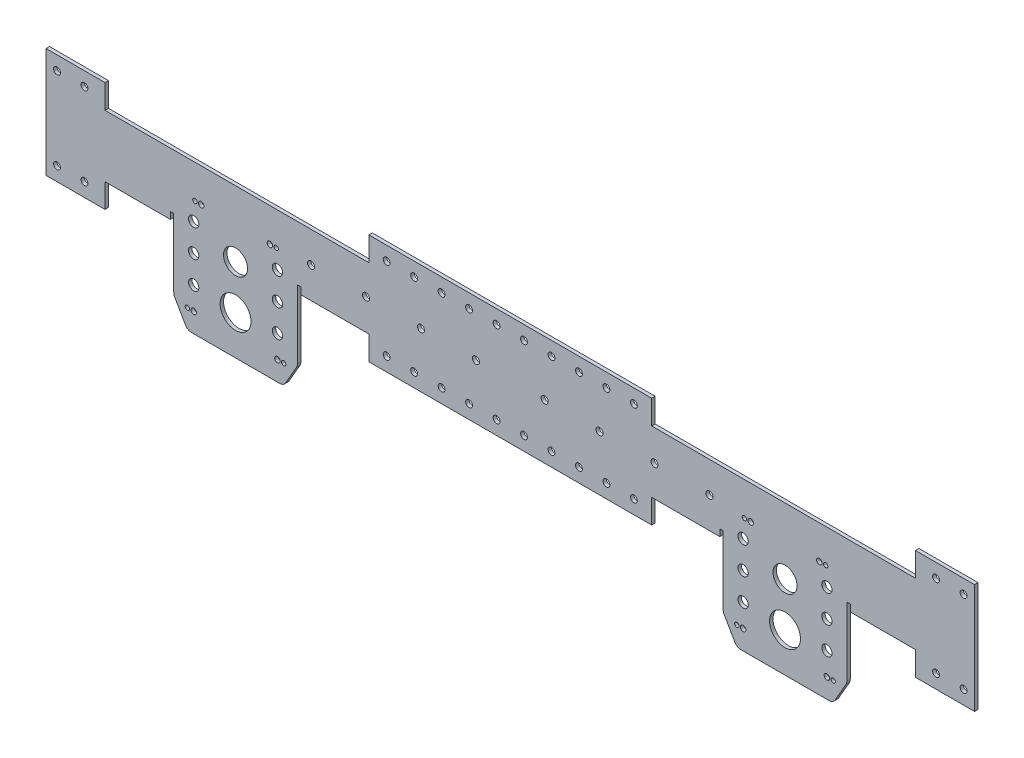
from build123d import *
from build123d.topology import SkipClean

# Parameters (mm, degrees)
SKETCH1_R            = 6.35
BOSS_EXTRUDE1_DEPTH  = 3.175
SKETCH2_W            = 596.9
SKETCH2_H            = 3.175
BOSS_EXTRUDE2_DEPTH  = 25.4
FILLET1_R            = 2.54
SKETCH3_R            = 3.2639
CUT_EXTRUDE1_DEPTH   = 25.4
SKETCH5_R            = 3.2639
CUT_EXTRUDE2_DEPTH   = 25.4
SKETCH6_W            = 31.75
SKETCH6_H            = 44.45
BOSS_EXTRUDE3_DEPTH  = 3.175
SKETCH7_W            = 31.75
SKETCH7_H            = 3.175
SKETCH7_W_2          = 381
BOSS_EXTRUDE4_DEPTH  = 25.4
FILLET2_R            = 2.54
SKETCH8_R            = 3.2639
CUT_EXTRUDE3_DEPTH   = 177.8
SKETCH9_R            = 3.2639
CUT_EXTRUDE5_DEPTH   = 432.308
BOSS_EXTRUDE6_DEPTH  = 66.675
BOSS_EXTRUDE7_START  = 66.675
BOSS_EXTRUDE7_DEPTH  = 66.675
SKETCH12_R           = 6.35
SKETCH12_R_2         = 3.2639
SKETCH12_W           = 256.6289
SKETCH12_H           = 252.715944366
CUT_EXTRUDE8_DEPTH   = 66.675
BOSS_EXTRUDE8_START  = 19.05
BOSS_EXTRUDE8_DEPTH  = 19.05
BOSS_EXTRUDE9_DEPTH  = 19.05
SKETCH16_R           = 3.2639
CUT_EXTRUDE9_DEPTH   = 133.096
SKETCH17_R           = 3.175
CUT_EXTRUDE11_DEPTH  = 5.08
SKETCH18_W           = 256.6289
SKETCH18_H           = 3.175
SKETCH18_W_2         = 838.2
BOSS_EXTRUDE10_DEPTH = 3.175
SKETCH19_W           = 107.950440108
SKETCH19_H           = 6.388661832
SKETCH19_W_2         = 107.95
SKETCH19_H_2         = 3.175
CUT_EXTRUDE12_DEPTH  = 3.175
SKETCH20_W           = 555.272296498
SKETCH20_H           = 244.428342312
SKETCH20_R           = 3.2639
SKETCH20_R_2         = 6.35
SKETCH20_R_3         = 3.175
CUT_EXTRUDE13_DEPTH  = 277.622
BOSS_EXTRUDE11_START = -3.175
SKETCH21_R           = 6.35
BOSS_EXTRUDE11_DEPTH = 3.175
SKETCH22_W           = 47.625
SKETCH22_H           = 22.225
SKETCH22_W_2         = 236.0422
BOSS_EXTRUDE12_DEPTH = 3.175
SKETCH23_W           = 47.625
SKETCH23_H           = 22.225
SKETCH23_W_2         = 236.0422
BOSS_EXTRUDE14_DEPTH = 3.175
BOSS_EXTRUDE15_DEPTH = 12.7
BOSS_EXTRUDE16_START = 12.7
BOSS_EXTRUDE16_DEPTH = 12.7
SKETCH27_R           = 3.175
CUT_EXTRUDE15_DEPTH  = 76.2
SKETCH28_W           = 22.225
SKETCH28_H           = 3.175
BOSS_EXTRUDE17_DEPTH = 12.7
SKETCH29_W           = 22.225
SKETCH29_H           = 3.175
BOSS_EXTRUDE18_DEPTH = 12.7
SKETCH30_R           = 6.35
SKETCH30_R_2         = 5.185373
SKETCH30_R_3         = 5.538595338
BOSS_EXTRUDE19_DEPTH = 3.175
SKETCH31_R           = 14.2875
SKETCH31_R_2         = 11.1125
SKETCH31_R_3         = 4.7625
SKETCH31_R_4         = 2.54
SKETCH31_R_5         = 2.032
CUT_EXTRUDE17_DEPTH  = 3.175
BOSS_EXTRUDE21_DEPTH = 3.175
FILLET4_R            = 6.35
SKETCH34_W           = 94.166192965
SKETCH34_H           = 14.648074461
BOSS_EXTRUDE22_DEPTH = 3.175
SKETCH35_R           = 2.54
SKETCH35_R_2         = 2.032
CUT_EXTRUDE19_DEPTH  = 3.175
SKETCH36_W           = 101.173518356
SKETCH36_H           = 13.169600398
BOSS_EXTRUDE24_DEPTH = 3.175
SKETCH37_W           = 9.525
SKETCH37_H           = 3.175
SKETCH37_W_2         = 3.175
CUT_EXTRUDE20_DEPTH  = 3.175
CUT_EXTRUDE21_START  = -3.175
CUT_EXTRUDE21_DEPTH  = 3.175
CUT_EXTRUDE22_DEPTH  = 3.175
CUT_EXTRUDE23_DEPTH  = 2.54
CUT_EXTRUDE24_START  = -2.54
CUT_EXTRUDE24_DEPTH  = 2.54
BOSS_EXTRUDE25_DEPTH = 3.175
SKETCH43_R           = 3.175
CUT_EXTRUDE25_DEPTH  = 3.175
SKETCH44_W           = 932.107852937
SKETCH44_H           = 79.647117721
CUT_EXTRUDE26_DEPTH  = 76.2


with BuildPart() as part:
    # Sketch1 → Boss-Extrude1 (new body)
    with BuildSketch(Plane.XY):
        with BuildLine():
            Line((50.8, 0), (50.8, 25.4))
            ThreePointArc((50.8, 25.4), (52.659871939, 29.890128061), (57.15, 31.75))
            Line((57.15, 31.75), (438.15, 31.75))
            ThreePointArc((438.15, 31.75), (442.640128061, 29.890128061), (444.5, 25.4))
            Line((444.5, 25.4), (444.5, 0))
            ThreePointArc((444.5, 0), (495.3, -50.8), (546.1, 0))
            Line((546.1, 0), (546.1, 76.2))
            Line((546.1, 76.2), (-50.8, 76.2))
            Line((-50.8, 76.2), (-50.8, 0))
            ThreePointArc((-50.8, 0), (0, -50.8), (50.8, 0))
        make_face()
        Circle(SKETCH1_R, mode=Mode.SUBTRACT)
        with Locations((495.3, 0)):
            Circle(SKETCH1_R, mode=Mode.SUBTRACT)
    extrude(amount=BOSS_EXTRUDE1_DEPTH)

    # Sketch2 → Boss-Extrude2 (add)
    with BuildSketch(Plane.XY.offset(3.175)):
        with Locations((247.65, 74.6125)):
            Rectangle(SKETCH2_W, SKETCH2_H)
    extrude(amount=BOSS_EXTRUDE2_DEPTH)

    # Fillet1
    fillet1_edges = [part.edges().sort_by_distance(p)[0] for p in [
        (247.65, 73.025, 3.175),
        (247.65, 76.2, 0),
    ]]
    fillet(fillet1_edges, radius=FILLET1_R)

    # Sketch3 → Cut-Extrude1 (cut)
    with BuildSketch(Plane(origin=(0, 76.2, 0), x_dir=(1, 0, 0), z_dir=(0, 1, 0))):
        with Locations((527.05, -15.5575)):
            Circle(SKETCH3_R)
        with Locations((501.65, -15.5575)):
            Circle(SKETCH3_R)
        with Locations((476.25, -15.5575)):
            Circle(SKETCH3_R)
        with Locations((450.85, -15.5575)):
            Circle(SKETCH3_R)
        with Locations((425.45, -15.5575)):
            Circle(SKETCH3_R)
        with Locations((400.05, -15.5575)):
            Circle(SKETCH3_R)
        with Locations((374.65, -15.5575)):
            Circle(SKETCH3_R)
        with Locations((349.25, -15.5575)):
            Circle(SKETCH3_R)
        with Locations((323.85, -15.5575)):
            Circle(SKETCH3_R)
        with Locations((298.45, -15.5575)):
            Circle(SKETCH3_R)
        with Locations((273.05, -15.5575)):
            Circle(SKETCH3_R)
        with Locations((247.65, -15.5575)):
            Circle(SKETCH3_R)
        with Locations((222.25, -15.5575)):
            Circle(SKETCH3_R)
        with Locations((196.85, -15.5575)):
            Circle(SKETCH3_R)
        with Locations((171.45, -15.5575)):
            Circle(SKETCH3_R)
        with Locations((146.05, -15.5575)):
            Circle(SKETCH3_R)
        with Locations((120.65, -15.5575)):
            Circle(SKETCH3_R)
        with Locations((95.25, -15.5575)):
            Circle(SKETCH3_R)
        with Locations((69.85, -15.5575)):
            Circle(SKETCH3_R)
        with Locations((44.45, -15.5575)):
            Circle(SKETCH3_R)
        with Locations((19.05, -15.5575)):
            Circle(SKETCH3_R)
        with Locations((-6.35, -15.5575)):
            Circle(SKETCH3_R)
        with Locations((-31.75, -15.5575)):
            Circle(SKETCH3_R)
    extrude(amount=-CUT_EXTRUDE1_DEPTH, mode=Mode.SUBTRACT)

    # Sketch5 → Cut-Extrude2 (cut)
    with BuildSketch(Plane(origin=(0, 0, 0), x_dir=(-1, 0, 0), z_dir=(0, 0, -1))):
        with Locations((-425.45, 53.975)):
            Circle(SKETCH5_R)
        with Locations((-374.65, 53.975)):
            Circle(SKETCH5_R)
        with Locations((-323.85, 53.975)):
            Circle(SKETCH5_R)
        with Locations((-273.05, 53.975)):
            Circle(SKETCH5_R)
        with Locations((-222.25, 53.975)):
            Circle(SKETCH5_R)
        with Locations((-171.45, 53.975)):
            Circle(SKETCH5_R)
        with Locations((-120.65, 53.975)):
            Circle(SKETCH5_R)
        with Locations((-69.85, 53.975)):
            Circle(SKETCH5_R)
    extrude(amount=-CUT_EXTRUDE2_DEPTH, mode=Mode.SUBTRACT)

    # Sketch6 → Boss-Extrude3 (add)
    with BuildSketch(Plane.XY.offset(3.175)):
        with Locations((-66.675, 53.975)):
            Rectangle(SKETCH6_W, SKETCH6_H)
        with Locations((561.975, 53.975)):
            Rectangle(SKETCH6_W, SKETCH6_H)
    extrude(amount=-BOSS_EXTRUDE3_DEPTH)

    # Sketch7 → Boss-Extrude4 (add)
    with BuildSketch(Plane.XY.offset(3.175)):
        with Locations((-66.675, 74.6125)):
            Rectangle(SKETCH7_W, SKETCH7_H)
        with Locations((-66.675, 33.3375)):
            Rectangle(SKETCH7_W, SKETCH7_H)
        with Locations((561.975, 74.6125)):
            Rectangle(SKETCH7_W, SKETCH7_H)
        with Locations((561.975, 33.3375)):
            Rectangle(SKETCH7_W, SKETCH7_H)
        with Locations((247.65, 33.3375)):
            Rectangle(SKETCH7_W_2, SKETCH7_H)
    extrude(amount=BOSS_EXTRUDE4_DEPTH)

    # Fillet2
    fillet2_edges = [part.edges().sort_by_distance(p)[0] for p in [
        (-50.8, 15.875, 0),
        (0, -50.8, 0),
        (50.8, 12.7, 0),
        (52.659871939, 29.890128061, 0),
        (546.1, 15.875, 0),
        (495.3, -50.8, 0),
        (444.5, 12.7, 0),
        (442.640128061, 29.890128061, 0),
        (-66.675, 34.925, 3.175),
        (-66.675, 31.75, 0),
        (247.65, 31.75, 0),
        (247.65, 34.925, 3.175),
        (561.975, 34.925, 3.175),
        (561.975, 31.75, 0),
        (561.975, 76.2, 0),
        (-66.675, 76.2, 0),
    ]]
    fillet(fillet2_edges, radius=FILLET2_R)

    # Sketch8 → Cut-Extrude3 (cut)
    with BuildSketch(Plane(origin=(0, 76.2, 0), x_dir=(1, 0, 0), z_dir=(0, 1, 0))):
        with Locations((-31.75, -15.5575)):
            Circle(SKETCH8_R)
        with Locations((-57.15, -15.5575)):
            Circle(SKETCH8_R)
        with Locations((-6.35, -15.5575)):
            Circle(SKETCH8_R)
        with Locations((19.05, -15.5575)):
            Circle(SKETCH8_R)
        with Locations((44.45, -15.5575)):
            Circle(SKETCH8_R)
        with Locations((69.85, -15.5575)):
            Circle(SKETCH8_R)
        with Locations((95.25, -15.5575)):
            Circle(SKETCH8_R)
        with Locations((120.65, -15.5575)):
            Circle(SKETCH8_R)
        with Locations((146.05, -15.5575)):
            Circle(SKETCH8_R)
        with Locations((171.45, -15.5575)):
            Circle(SKETCH8_R)
        with Locations((196.85, -15.5575)):
            Circle(SKETCH8_R)
        with Locations((222.25, -15.5575)):
            Circle(SKETCH8_R)
        with Locations((247.65, -15.5575)):
            Circle(SKETCH8_R)
        with Locations((273.05, -15.5575)):
            Circle(SKETCH8_R)
        with Locations((298.45, -15.5575)):
            Circle(SKETCH8_R)
        with Locations((323.85, -15.5575)):
            Circle(SKETCH8_R)
        with Locations((349.25, -15.5575)):
            Circle(SKETCH8_R)
        with Locations((374.65, -15.5575)):
            Circle(SKETCH8_R)
        with Locations((400.05, -15.5575)):
            Circle(SKETCH8_R)
        with Locations((425.45, -15.5575)):
            Circle(SKETCH8_R)
        with Locations((450.85, -15.5575)):
            Circle(SKETCH8_R)
        with Locations((476.25, -15.5575)):
            Circle(SKETCH8_R)
        with Locations((501.65, -15.5575)):
            Circle(SKETCH8_R)
        with Locations((527.05, -15.5575)):
            Circle(SKETCH8_R)
        with Locations((552.45, -15.5575)):
            Circle(SKETCH8_R)
    extrude(amount=-CUT_EXTRUDE3_DEPTH, mode=Mode.SUBTRACT)

    # Sketch9 → Cut-Extrude5 (cut)
    with BuildSketch(Plane(origin=(0, 76.2, 0), x_dir=(1, 0, 0), z_dir=(0, 1, 0))):
        with BuildLine():
            Line((298.45, -18.8214), (298.45, -28.575))
            Line((298.45, -28.575), (746.392900795, -28.575))
            Line((746.392900795, -28.575), (746.392900795, 89.004110939))
            Line((746.392900795, 89.004110939), (298.45, 89.004110939))
            Line((298.45, 89.004110939), (298.45, -12.2936))
            ThreePointArc((298.45, -12.2936), (301.7139, -15.5575), (298.45, -18.8214))
        make_face()
        with Locations((323.85, -15.5575)):
            Circle(SKETCH9_R, mode=Mode.SUBTRACT)
        with Locations((349.25, -15.5575)):
            Circle(SKETCH9_R, mode=Mode.SUBTRACT)
        with Locations((374.65, -15.5575)):
            Circle(SKETCH9_R, mode=Mode.SUBTRACT)
        with Locations((400.05, -15.5575)):
            Circle(SKETCH9_R, mode=Mode.SUBTRACT)
        with Locations((425.45, -15.5575)):
            Circle(SKETCH9_R, mode=Mode.SUBTRACT)
        with Locations((450.85, -15.5575)):
            Circle(SKETCH9_R, mode=Mode.SUBTRACT)
        with Locations((476.25, -15.5575)):
            Circle(SKETCH9_R, mode=Mode.SUBTRACT)
        with Locations((501.65, -15.5575)):
            Circle(SKETCH9_R, mode=Mode.SUBTRACT)
        with Locations((527.05, -15.5575)):
            Circle(SKETCH9_R, mode=Mode.SUBTRACT)
        with Locations((552.45, -15.5575)):
            Circle(SKETCH9_R, mode=Mode.SUBTRACT)
    extrude(amount=-CUT_EXTRUDE5_DEPTH, mode=Mode.SUBTRACT)

    # Mirror4: part across plane


with BuildPart() as part_1:
    with SkipClean():  # the faces are left unmerged after this step: merging them gives an invalid solid
        add(part.part)
        add(part.part.mirror(Plane(origin=(298.45, -356.108, 0), x_dir=(0, 0, 1), z_dir=(1, 0, 0))))

    # Sketch10 → Boss-Extrude6 (add)
    with SkipClean():  # the faces are left unmerged after this step: merging them gives an invalid solid
        with BuildSketch(Plane.ZY.offset(82.55)):
            with BuildLine():
                Line((0, 73.66), (0, 34.29))
                ThreePointArc((0, 34.29), (0.743948776, 32.493948776), (2.54, 31.75))
                Line((2.54, 31.75), (28.575, 31.75))
                Line((28.575, 31.75), (28.575, 34.925))
                Line((28.575, 34.925), (5.715, 34.925))
                ThreePointArc((5.715, 34.925), (3.918948776, 35.668948776), (3.175, 37.465))
                Line((3.175, 37.465), (3.175, 73.025))
                Line((3.175, 73.025), (28.575, 73.025))
                Line((28.575, 73.025), (28.575, 76.2))
                Line((28.575, 76.2), (2.54, 76.2))
                ThreePointArc((2.54, 76.2), (0.743948776, 75.456051224), (0, 73.66))
            make_face()
        extrude(amount=BOSS_EXTRUDE6_DEPTH)

    # Sketch11 → Boss-Extrude7 (add)
    with SkipClean():  # the faces are left unmerged after this step: merging them gives an invalid solid
        with BuildSketch(Plane(origin=(679.45, 0, 0), x_dir=(0, 0, -1), z_dir=(1, 0, 0)).offset(BOSS_EXTRUDE7_START)):
            with BuildLine():
                Line((0, 34.29), (0, 73.66))
                ThreePointArc((0, 73.66), (-0.743948776, 75.456051224), (-2.54, 76.2))
                Line((-2.54, 76.2), (-28.575, 76.2))
                Line((-28.575, 76.2), (-28.575, 73.025))
                Line((-28.575, 73.025), (-3.175, 73.025))
                Line((-3.175, 73.025), (-3.175, 37.465))
                ThreePointArc((-3.175, 37.465), (-3.918948776, 35.668948776), (-5.715, 34.925))
                Line((-5.715, 34.925), (-28.575, 34.925))
                Line((-28.575, 34.925), (-28.575, 31.75))
                Line((-28.575, 31.75), (-2.54, 31.75))
                ThreePointArc((-2.54, 31.75), (-0.743948776, 32.493948776), (0, 34.29))
            make_face()
        extrude(amount=-BOSS_EXTRUDE7_DEPTH)

    # Sketch12 → Cut-Extrude8 (cut)
    # profile 1 of 2: a face of its own
    with SkipClean():  # the faces are left unmerged after this step: merging them gives an invalid solid
        with BuildSketch(Plane.XY.offset(3.175)):
            with BuildLine():
                Line((135.9789, 114.3), (-120.65, 114.3))
                Line((-120.65, 114.3), (-120.65, -7.986269461))
                Line((-120.65, -7.986269461), (-114.3, -7.986269461))
                Line((-114.3, -7.986269461), (-114.3, 0))
                ThreePointArc((-114.3, 0), (0, -114.3), (114.3, 0))
                Line((114.3, 0), (114.3, -15.458780647))
                Line((114.3, -15.458780647), (135.9789, -15.458780647))
                Line((135.9789, -15.458780647), (135.9789, 114.3))
            make_face()
            Circle(SKETCH12_R, mode=Mode.SUBTRACT)
            with Locations((69.85, 53.975)):
                Circle(SKETCH12_R_2, mode=Mode.SUBTRACT)
            with Locations((120.65, 53.975)):
                Circle(SKETCH12_R_2, mode=Mode.SUBTRACT)
        # profile 2 of 2: a face of its own
        with BuildSketch(Plane.XY.offset(3.175)):
            with Locations((589.23555, 8.748218221)):
                Rectangle(SKETCH12_W, SKETCH12_H)
            with Locations((596.9, 0)):
                Circle(SKETCH12_R, mode=Mode.SUBTRACT)
            with Locations((476.25, 53.975)):
                Circle(SKETCH12_R_2, mode=Mode.SUBTRACT)
            with Locations((527.05, 53.975)):
                Circle(SKETCH12_R_2, mode=Mode.SUBTRACT)
        extrude(amount=CUT_EXTRUDE8_DEPTH, mode=Mode.SUBTRACT)

    # Sketch14 → Boss-Extrude8 (add)
    with SkipClean():  # the faces are left unmerged after this step: merging them gives an invalid solid
        with BuildSketch(Plane(origin=(746.125, 0, 0), x_dir=(0, 0, -1), z_dir=(1, 0, 0)).offset(BOSS_EXTRUDE8_START)):
            with BuildLine():
                Line((0, 34.29), (0, 73.66))
                ThreePointArc((0, 73.66), (-0.743948776, 75.456051224), (-2.54, 76.2))
                Line((-2.54, 76.2), (-28.575, 76.2))
                Line((-28.575, 76.2), (-28.575, 73.025))
                Line((-28.575, 73.025), (-3.175, 73.025))
                Line((-3.175, 73.025), (-3.175, 37.465))
                ThreePointArc((-3.175, 37.465), (-3.918948776, 35.668948776), (-5.715, 34.925))
                Line((-5.715, 34.925), (-28.575, 34.925))
                Line((-28.575, 34.925), (-28.575, 31.75))
                Line((-28.575, 31.75), (-2.54, 31.75))
                ThreePointArc((-2.54, 31.75), (-0.743948776, 32.493948776), (0, 34.29))
            make_face()
        extrude(amount=-BOSS_EXTRUDE8_DEPTH)

    # Sketch15 → Boss-Extrude9 (add)
    with SkipClean():  # the faces are left unmerged after this step: merging them gives an invalid solid
        with BuildSketch(Plane.ZY.offset(149.225)):
            with BuildLine():
                Line((0, 73.66), (0, 34.29))
                ThreePointArc((0, 34.29), (0.743948776, 32.493948776), (2.54, 31.75))
                Line((2.54, 31.75), (28.575, 31.75))
                Line((28.575, 31.75), (28.575, 34.925))
                Line((28.575, 34.925), (5.715, 34.925))
                ThreePointArc((5.715, 34.925), (3.918948776, 35.668948776), (3.175, 37.465))
                Line((3.175, 37.465), (3.175, 73.025))
                Line((3.175, 73.025), (28.575, 73.025))
                Line((28.575, 73.025), (28.575, 76.2))
                Line((28.575, 76.2), (2.54, 76.2))
                ThreePointArc((2.54, 76.2), (0.743948776, 75.456051224), (0, 73.66))
            make_face()
        extrude(amount=BOSS_EXTRUDE9_DEPTH)

    # Sketch16 → Cut-Extrude9 (cut)
    with SkipClean():  # the faces are left unmerged after this step: merging them gives an invalid solid
        with BuildSketch(Plane(origin=(0, 76.2, 0), x_dir=(1, 0, 0), z_dir=(0, 1, 0))):
            with Locations((146.05, -15.5575)):
                Circle(SKETCH16_R)
            with Locations((171.45, -15.5575)):
                Circle(SKETCH16_R)
            with Locations((196.85, -15.5575)):
                Circle(SKETCH16_R)
            with Locations((222.25, -15.5575)):
                Circle(SKETCH16_R)
            with Locations((247.65, -15.5575)):
                Circle(SKETCH16_R)
            with Locations((273.05, -15.5575)):
                Circle(SKETCH16_R)
            with Locations((298.45, -15.5575)):
                Circle(SKETCH16_R)
            with Locations((323.85, -15.5575)):
                Circle(SKETCH16_R)
            with Locations((349.25, -15.5575)):
                Circle(SKETCH16_R)
            with Locations((374.65, -15.5575)):
                Circle(SKETCH16_R)
            with Locations((400.05, -15.5575)):
                Circle(SKETCH16_R)
            with Locations((425.45, -15.5575)):
                Circle(SKETCH16_R)
            with Locations((450.85, -15.5575)):
                Circle(SKETCH16_R)
            with Locations((476.25, -15.5575)):
                Circle(SKETCH16_R)
            with Locations((501.65, -15.5575)):
                Circle(SKETCH16_R)
            with Locations((527.05, -15.5575)):
                Circle(SKETCH16_R)
            with Locations((552.45, -15.5575)):
                Circle(SKETCH16_R)
            with Locations((577.85, -15.5575)):
                Circle(SKETCH16_R)
            with Locations((603.25, -15.5575)):
                Circle(SKETCH16_R)
            with Locations((628.65, -15.5575)):
                Circle(SKETCH16_R)
            with Locations((654.05, -15.5575)):
                Circle(SKETCH16_R)
            with Locations((679.45, -15.5575)):
                Circle(SKETCH16_R)
            with Locations((704.85, -15.5575)):
                Circle(SKETCH16_R)
            with Locations((730.25, -15.5575)):
                Circle(SKETCH16_R)
            with Locations((755.65, -15.5575)):
                Circle(SKETCH16_R)
            with Locations((120.65, -15.5575)):
                Circle(SKETCH16_R)
            with Locations((95.25, -15.5575)):
                Circle(SKETCH16_R)
            with Locations((69.85, -15.5575)):
                Circle(SKETCH16_R)
            with Locations((44.45, -15.5575)):
                Circle(SKETCH16_R)
            with Locations((19.05, -15.5575)):
                Circle(SKETCH16_R)
            with Locations((-6.35, -15.5575)):
                Circle(SKETCH16_R)
            with Locations((-31.75, -15.5575)):
                Circle(SKETCH16_R)
            with Locations((-57.15, -15.5575)):
                Circle(SKETCH16_R)
            with Locations((-82.55, -15.5575)):
                Circle(SKETCH16_R)
            with Locations((-107.95, -15.5575)):
                Circle(SKETCH16_R)
            with Locations((-133.35, -15.5575)):
                Circle(SKETCH16_R)
            with Locations((-158.75, -15.5575)):
                Circle(SKETCH16_R)
        extrude(amount=-CUT_EXTRUDE9_DEPTH, mode=Mode.SUBTRACT)

    # Sketch17 → Cut-Extrude11 (cut)
    with SkipClean():  # the faces are left unmerged after this step: merging them gives an invalid solid
        with BuildSketch(Plane(origin=(0, 0, 0), x_dir=(-1, 0, 0), z_dir=(0, 0, -1))):
            with Locations((0, 63.5)):
                Circle(SKETCH17_R)
            with Locations((-596.9, 63.5)):
                Circle(SKETCH17_R)
        extrude(amount=-CUT_EXTRUDE11_DEPTH, mode=Mode.SUBTRACT)

    # Sketch18 → Boss-Extrude10 (add)
    with SkipClean():  # the faces are left unmerged after this step: merging them gives an invalid solid
        with BuildSketch(Plane.XY.offset(3.175)):
            with Locations((7.66445, 74.6125)):
                Rectangle(SKETCH18_W, SKETCH18_H)
            with Locations((589.23555, 74.6125)):
                Rectangle(SKETCH18_W, SKETCH18_H)
            with Locations((298.45, 33.3375)):
                Rectangle(SKETCH18_W_2, SKETCH18_H)
        extrude(amount=BOSS_EXTRUDE10_DEPTH)

    # Sketch19 → Cut-Extrude12 (cut)
    with SkipClean():  # the faces are left unmerged after this step: merging them gives an invalid solid
        with BuildSketch(Plane.XY.offset(3.175)):
            with Locations((3.175220054, 34.944330916)):
                Rectangle(SKETCH19_W, SKETCH19_H)
            with Locations((593.725, 33.3375)):
                Rectangle(SKETCH19_W_2, SKETCH19_H_2)
        extrude(amount=CUT_EXTRUDE12_DEPTH, mode=Mode.SUBTRACT)

    # Sketch20 → Cut-Extrude13 (cut)
    with BuildSketch(Plane(origin=(0, 0, 0), x_dir=(-1, 0, 0), z_dir=(0, 0, -1))):
        with Locations((-65.263851751, 61.916295681)):
            Rectangle(SKETCH20_W, SKETCH20_H)
        with Locations((-323.85, 53.975)):
            Circle(SKETCH20_R, mode=Mode.SUBTRACT)
        with Locations((-273.05, 53.975)):
            Circle(SKETCH20_R, mode=Mode.SUBTRACT)
        with Locations((-222.25, 53.975)):
            Circle(SKETCH20_R, mode=Mode.SUBTRACT)
        with Locations((-171.45, 53.975)):
            Circle(SKETCH20_R, mode=Mode.SUBTRACT)
        with Locations((-120.65, 53.975)):
            Circle(SKETCH20_R, mode=Mode.SUBTRACT)
        with Locations((-69.85, 53.975)):
            Circle(SKETCH20_R, mode=Mode.SUBTRACT)
        Circle(SKETCH20_R_2, mode=Mode.SUBTRACT)
        with Locations((0, 63.5)):
            Circle(SKETCH20_R_3, mode=Mode.SUBTRACT)
    extrude(amount=-CUT_EXTRUDE13_DEPTH, mode=Mode.SUBTRACT)

    # Sketch21 → Boss-Extrude11 (add)
    with BuildSketch(Plane.XY.offset(3.175).offset(BOSS_EXTRUDE11_START)):
        with BuildLine():
            Line((546.1, 0), (546.1, 25.4))
            ThreePointArc((546.1, 25.4), (544.240128061, 29.890128061), (539.75, 31.75))
            Line((539.75, 31.75), (539.75, 34.925))
            Line((539.75, 34.925), (647.7, 34.925))
            Line((647.7, 34.925), (647.7, 31.75))
            Line((647.7, 31.75), (647.7, 0))
            ThreePointArc((647.7, 0), (596.9, -50.8), (546.1, 0))
        make_face()
        with Locations((596.9, 0)):
            Circle(SKETCH21_R, mode=Mode.SUBTRACT)
    extrude(amount=BOSS_EXTRUDE11_DEPTH)

    # Mirror5: part across plane


with BuildPart() as part_2:
    add(part_1.part)
    add(part_1.part.mirror(Plane(origin=(342.9, 0, 277.622), x_dir=(0, 0, 1), z_dir=(1, 0, 0))))

    # Sketch22 → Boss-Extrude12 (add)
    with BuildSketch(Plane(origin=(0, 76.2, 0), x_dir=(1, 0, 0), z_dir=(0, 1, 0))):
        with Locations((741.3625, -17.4625)):
            Rectangle(SKETCH22_W, SKETCH22_H)
        with Locations((342.9, -17.4625)):
            Rectangle(SKETCH22_W_2, SKETCH22_H)
        with Locations((-55.5625, -17.4625)):
            Rectangle(SKETCH22_W, SKETCH22_H)
    extrude(amount=-BOSS_EXTRUDE12_DEPTH)

    # Sketch23 → Boss-Extrude14 (add)
    with BuildSketch(Plane.XZ.offset(-31.75)):
        with Locations((-55.5625, 17.4625)):
            Rectangle(SKETCH23_W, SKETCH23_H)
        with Locations((342.9, 17.4625)):
            Rectangle(SKETCH23_W_2, SKETCH23_H)
        with Locations((741.3625, 17.4625)):
            Rectangle(SKETCH23_W, SKETCH23_H)
    extrude(amount=-BOSS_EXTRUDE14_DEPTH)

    # Sketch25 → Boss-Extrude15 (add)
    with BuildSketch(Plane.ZY.offset(79.375)):
        with BuildLine():
            Line((2.54, 31.75), (28.575, 31.75))
            Line((28.575, 31.75), (28.575, 34.925))
            Line((28.575, 34.925), (5.715, 34.925))
            ThreePointArc((5.715, 34.925), (3.918948776, 35.668948776), (3.175, 37.465))
            Line((3.175, 37.465), (3.175, 73.025))
            Line((3.175, 73.025), (28.575, 73.025))
            Line((28.575, 73.025), (28.575, 76.2))
            Line((28.575, 76.2), (2.54, 76.2))
            ThreePointArc((2.54, 76.2), (0.743948776, 75.456051224), (0, 73.66))
            Line((0, 73.66), (0, 34.29))
            ThreePointArc((0, 34.29), (0.743948776, 32.493948776), (2.54, 31.75))
        make_face()
    extrude(amount=BOSS_EXTRUDE15_DEPTH)

    # Sketch26 → Boss-Extrude16 (add)
    with BuildSketch(Plane(origin=(765.175, 0, 0), x_dir=(0, 0, -1), z_dir=(1, 0, 0)).offset(BOSS_EXTRUDE16_START)):
        with BuildLine():
            Line((-5.715, 34.925), (-28.575, 34.925))
            Line((-28.575, 34.925), (-28.575, 31.75))
            Line((-28.575, 31.75), (-2.54, 31.75))
            ThreePointArc((-2.54, 31.75), (-0.743948776, 32.493948776), (0, 34.29))
            Line((0, 34.29), (0, 73.66))
            ThreePointArc((0, 73.66), (-0.743948776, 75.456051224), (-2.54, 76.2))
            Line((-2.54, 76.2), (-28.575, 76.2))
            Line((-28.575, 76.2), (-28.575, 73.025))
            Line((-28.575, 73.025), (-3.175, 73.025))
            Line((-3.175, 73.025), (-3.175, 37.465))
            ThreePointArc((-3.175, 37.465), (-3.918948776, 35.668948776), (-5.715, 34.925))
        make_face()
    extrude(amount=-BOSS_EXTRUDE16_DEPTH)

    # Sketch27 → Cut-Extrude15 (cut)
    with BuildSketch(Plane(origin=(0, 76.2, 0), x_dir=(1, 0, 0), z_dir=(0, 1, 0))):
        with Locations((762, -15.788044632)):
            Circle(SKETCH27_R)
        with Locations((736.6, -15.788044632)):
            Circle(SKETCH27_R)
        with Locations((711.2, -15.788044632)):
            Circle(SKETCH27_R)
        with Locations((685.8, -15.788044632)):
            Circle(SKETCH27_R)
        with Locations((660.4, -15.788044632)):
            Circle(SKETCH27_R)
        with Locations((635, -15.788044632)):
            Circle(SKETCH27_R)
        with Locations((609.6, -15.788044632)):
            Circle(SKETCH27_R)
        with Locations((584.2, -15.788044632)):
            Circle(SKETCH27_R)
        with Locations((558.8, -15.788044632)):
            Circle(SKETCH27_R)
        with Locations((533.4, -15.788044632)):
            Circle(SKETCH27_R)
        with Locations((508, -15.788044632)):
            Circle(SKETCH27_R)
        with Locations((482.6, -15.788044632)):
            Circle(SKETCH27_R)
        with Locations((457.2, -15.788044632)):
            Circle(SKETCH27_R)
        with Locations((431.8, -15.788044632)):
            Circle(SKETCH27_R)
        with Locations((406.4, -15.788044632)):
            Circle(SKETCH27_R)
        with Locations((381, -15.788044632)):
            Circle(SKETCH27_R)
        with Locations((355.6, -15.788044632)):
            Circle(SKETCH27_R)
        with Locations((330.2, -15.788044632)):
            Circle(SKETCH27_R)
        with Locations((304.8, -15.788044632)):
            Circle(SKETCH27_R)
        with Locations((279.4, -15.788044632)):
            Circle(SKETCH27_R)
        with Locations((254, -15.788044632)):
            Circle(SKETCH27_R)
        with Locations((228.6, -15.788044632)):
            Circle(SKETCH27_R)
        with Locations((203.2, -15.788044632)):
            Circle(SKETCH27_R)
        with Locations((177.8, -15.788044632)):
            Circle(SKETCH27_R)
        with Locations((152.4, -15.788044632)):
            Circle(SKETCH27_R)
        with Locations((127, -15.788044632)):
            Circle(SKETCH27_R)
        with Locations((101.6, -15.788044632)):
            Circle(SKETCH27_R)
        with Locations((76.2, -15.788044632)):
            Circle(SKETCH27_R)
        with Locations((50.8, -15.788044632)):
            Circle(SKETCH27_R)
        with Locations((25.4, -15.788044632)):
            Circle(SKETCH27_R)
        with Locations((0, -15.788044632)):
            Circle(SKETCH27_R)
        with Locations((-25.4, -15.788044632)):
            Circle(SKETCH27_R)
        with Locations((-50.8, -15.788044632)):
            Circle(SKETCH27_R)
        with Locations((-76.2, -15.788044632)):
            Circle(SKETCH27_R)
    extrude(amount=-CUT_EXTRUDE15_DEPTH, mode=Mode.SUBTRACT)

    # Sketch28 → Boss-Extrude17 (add)
    with BuildSketch(Plane.ZY.offset(-224.8789)):
        with Locations((17.4625, 74.6125)):
            Rectangle(SKETCH28_W, SKETCH28_H)
        with Locations((17.4625, 33.3375)):
            Rectangle(SKETCH28_W, SKETCH28_H)
    extrude(amount=BOSS_EXTRUDE17_DEPTH)

    # Sketch29 → Boss-Extrude18 (add)
    with BuildSketch(Plane(origin=(460.9211, 0, 0), x_dir=(0, 0, -1), z_dir=(1, 0, 0))):
        with Locations((-17.4625, 74.6125)):
            Rectangle(SKETCH29_W, SKETCH29_H)
        with Locations((-17.4625, 33.3375)):
            Rectangle(SKETCH29_W, SKETCH29_H)
    extrude(amount=BOSS_EXTRUDE18_DEPTH)

    # Sketch30 → Boss-Extrude19 (add)
    with BuildSketch(Plane(origin=(0, 0, 0), x_dir=(-1, 0, 0), z_dir=(0, 0, -1))):
        with Locations((-88.9, 0)):
            Circle(SKETCH30_R)
        with Locations((-596.9, 0)):
            Circle(SKETCH30_R)
        with Locations((-596.9, 63.862726265)):
            Circle(SKETCH30_R_2)
        with Locations((-88.9, 63.5)):
            Circle(SKETCH30_R_3)
    extrude(amount=-BOSS_EXTRUDE19_DEPTH)

    # Sketch31 → Cut-Extrude17 (cut)
    with BuildSketch(Plane(origin=(0, 0, 0), x_dir=(-1, 0, 0), z_dir=(0, 0, -1))):
        with Locations((-596.9, -19.05)):
            Circle(SKETCH31_R)
        with Locations((-596.9, 21.6408)):
            Circle(SKETCH31_R_2)
        with Locations((-558.17570279, 9.144)):
            Circle(SKETCH31_R_3)
        with Locations((-558.17570279, 34.544)):
            Circle(SKETCH31_R_3)
        with Locations((-558.17570279, -16.256)):
            Circle(SKETCH31_R_3)
        with Locations((-565.15, 57.205147634)):
            Circle(SKETCH31_R_4)
        with Locations((-559.308, 57.205147634)):
            Circle(SKETCH31_R_5)
        with Locations((-635.62429721, -16.256)):
            Circle(SKETCH31_R_3)
        with Locations((-635.62429721, 9.144)):
            Circle(SKETCH31_R_3)
        with Locations((-634.492, 57.205147634)):
            Circle(SKETCH31_R_5)
        with Locations((-628.65, 57.205147634)):
            Circle(SKETCH31_R_4)
        with Locations((-635.62429721, 34.544)):
            Circle(SKETCH31_R_3)
        with Locations((-50.17570279, -16.256)):
            Circle(SKETCH31_R_3)
        with Locations((-50.17570279, 9.144)):
            Circle(SKETCH31_R_3)
        with Locations((-50.17570279, 34.544)):
            Circle(SKETCH31_R_3)
        with Locations((-51.308, 57.205147634)):
            Circle(SKETCH31_R_5)
        with Locations((-57.15, 57.205147634)):
            Circle(SKETCH31_R_4)
        with Locations((-88.9, 21.6408)):
            Circle(SKETCH31_R_2)
        with Locations((-126.492, 57.205147634)):
            Circle(SKETCH31_R_5)
        with Locations((-120.65, 57.205147634)):
            Circle(SKETCH31_R_4)
        with Locations((-127.62429721, 34.544)):
            Circle(SKETCH31_R_3)
        with Locations((-127.62429721, 9.144)):
            Circle(SKETCH31_R_3)
        with Locations((-127.62429721, -16.256)):
            Circle(SKETCH31_R_3)
        with Locations((-88.9, -19.05)):
            Circle(SKETCH31_R)
    extrude(amount=-CUT_EXTRUDE17_DEPTH, mode=Mode.SUBTRACT)

    # Sketch33 → Boss-Extrude21 (add)
    with BuildSketch(Plane(origin=(0, 0, 0), x_dir=(-1, 0, 0), z_dir=(0, 0, -1))):
        with BuildLine():
            Line((-654.05, -33.374954744), (-641.35, -55.372))
            Line((-641.35, -55.372), (-552.45, -55.372))
            Line((-552.45, -55.372), (-539.75, -33.374954744))
            Line((-539.75, -33.374954744), (-539.75, 31.75))
            ThreePointArc((-539.75, 31.75), (-544.240128061, 29.890128061), (-546.1, 25.4))
            Line((-546.1, 25.4), (-546.1, 0))
            ThreePointArc((-546.1, 0), (-596.9, -50.8), (-647.7, 0))
            Line((-647.7, 0), (-647.7, 34.29))
            Line((-647.7, 34.29), (-654.05, 34.29))
            Line((-654.05, 34.29), (-654.05, -33.374954744))
        make_face()
        with BuildLine():
            Line((-139.7, 0), (-139.7, 25.4))
            ThreePointArc((-139.7, 25.4), (-141.559871939, 29.890128061), (-146.05, 31.75))
            Line((-146.05, 31.75), (-146.05, -33.374954744))
            Line((-146.05, -33.374954744), (-133.35, -55.372))
            Line((-133.35, -55.372), (-44.45, -55.372))
            Line((-44.45, -55.372), (-31.75, -33.374954744))
            Line((-31.75, -33.374954744), (-31.75, 34.29))
            Line((-31.75, 34.29), (-38.1, 34.29))
            Line((-38.1, 34.29), (-38.1, 0))
            ThreePointArc((-38.1, 0), (-88.9, -50.8), (-139.7, 0))
        make_face()
    extrude(amount=-BOSS_EXTRUDE21_DEPTH)

    # Fillet4
    fillet4_edges = [part_2.edges().sort_by_distance(p)[0] for p in [
        (146.05, -33.374954744, 1.5875),
        (133.35, -55.372, 1.5875),
        (44.45, -55.372, 1.5875),
        (31.75, -33.374954744, 1.5875),
        (539.75, -33.374954744, 1.5875),
        (552.45, -55.372, 1.5875),
        (641.35, -55.372, 1.5875),
        (654.05, -33.374954744, 1.5875),
    ]]
    fillet(fillet4_edges, radius=FILLET4_R)

    # Sketch34 → Boss-Extrude22 (add)
    with BuildSketch(Plane.XY.offset(3.175)):
        with Locations((84.981170213, 57.98826549)):
            Rectangle(SKETCH34_W, SKETCH34_H)
    extrude(amount=-BOSS_EXTRUDE22_DEPTH)

    # Sketch35 → Cut-Extrude19 (cut)
    with BuildSketch(Plane.XY.offset(3.175)):
        with Locations((120.65, 51.53152)):
            Circle(SKETCH35_R)
        with Locations((126.492, 51.53152)):
            Circle(SKETCH35_R_2)
        with Locations((127.62429721, -37.36086)):
            Circle(SKETCH35_R)
        with Locations((133.46629721, -37.36086)):
            Circle(SKETCH35_R_2)
        with Locations((44.33370279, -37.36086)):
            Circle(SKETCH35_R_2)
        with Locations((50.17570279, -37.36086)):
            Circle(SKETCH35_R)
        with Locations((51.308, 51.53152)):
            Circle(SKETCH35_R_2)
        with Locations((57.15, 51.53152)):
            Circle(SKETCH35_R)
        with Locations((628.65, 51.53152)):
            Circle(SKETCH35_R)
        with Locations((634.492, 51.53152)):
            Circle(SKETCH35_R_2)
        with Locations((635.62429721, -37.36086)):
            Circle(SKETCH35_R)
        with Locations((641.46629721, -37.36086)):
            Circle(SKETCH35_R_2)
        with Locations((552.33370279, -37.36086)):
            Circle(SKETCH35_R_2)
        with Locations((558.17570279, -37.36086)):
            Circle(SKETCH35_R)
        with Locations((559.308, 51.53152)):
            Circle(SKETCH35_R_2)
        with Locations((565.15, 51.53152)):
            Circle(SKETCH35_R)
    extrude(amount=-CUT_EXTRUDE19_DEPTH, mode=Mode.SUBTRACT)

    # Sketch36 → Boss-Extrude24 (add)
    with BuildSketch(Plane.XY.offset(3.175)):
        with Locations((602.956965064, 61.018078597)):
            Rectangle(SKETCH36_W, SKETCH36_H)
    extrude(amount=-BOSS_EXTRUDE24_DEPTH)

    # Sketch37 → Cut-Extrude20 (cut)
    with BuildSketch(Plane.XY.offset(3.175)):
        with Locations((33.3375, 33.3375)):
            Rectangle(SKETCH37_W, SKETCH37_H)
        with Locations((147.6375, 33.3375)):
            Rectangle(SKETCH37_W_2, SKETCH37_H)
        with Locations((652.4625, 33.3375)):
            Rectangle(SKETCH37_W, SKETCH37_H)
        with Locations((538.1625, 33.3375)):
            Rectangle(SKETCH37_W_2, SKETCH37_H)
    extrude(amount=CUT_EXTRUDE20_DEPTH, mode=Mode.SUBTRACT)

    # Sketch38 → Cut-Extrude21 (cut)
    with BuildSketch(Plane.ZY.offset(92.075).offset(CUT_EXTRUDE21_START)):
        with BuildLine():
            Line((2.54, 31.75), (28.575, 31.75))
            Line((28.575, 31.75), (28.575, 34.925))
            Line((28.575, 34.925), (5.715, 34.925))
            ThreePointArc((5.715, 34.925), (3.918948776, 35.668948776), (3.175, 37.465))
            Line((3.175, 37.465), (3.175, 73.025))
            Line((3.175, 73.025), (28.575, 73.025))
            Line((28.575, 73.025), (28.575, 76.2))
            Line((28.575, 76.2), (2.54, 76.2))
            ThreePointArc((2.54, 76.2), (0.743948776, 75.456051224), (0, 73.66))
            Line((0, 73.66), (0, 34.29))
            ThreePointArc((0, 34.29), (0.743948776, 32.493948776), (2.54, 31.75))
        make_face()
    extrude(amount=CUT_EXTRUDE21_DEPTH, mode=Mode.SUBTRACT)

    # Sketch39 → Cut-Extrude22 (cut)
    with BuildSketch(Plane(origin=(777.875, 0, 0), x_dir=(0, 0, -1), z_dir=(1, 0, 0))):
        with BuildLine():
            Line((-5.715, 34.925), (-28.575, 34.925))
            Line((-28.575, 34.925), (-28.575, 31.75))
            Line((-28.575, 31.75), (-2.54, 31.75))
            ThreePointArc((-2.54, 31.75), (-0.743948776, 32.493948776), (0, 34.29))
            Line((0, 34.29), (0, 73.66))
            ThreePointArc((0, 73.66), (-0.743948776, 75.456051224), (-2.54, 76.2))
            Line((-2.54, 76.2), (-28.575, 76.2))
            Line((-28.575, 76.2), (-28.575, 73.025))
            Line((-28.575, 73.025), (-3.175, 73.025))
            Line((-3.175, 73.025), (-3.175, 37.465))
            ThreePointArc((-3.175, 37.465), (-3.918948776, 35.668948776), (-5.715, 34.925))
        make_face()
    extrude(amount=-CUT_EXTRUDE22_DEPTH, mode=Mode.SUBTRACT)

    # Sketch40 → Cut-Extrude23 (cut)
    with BuildSketch(Plane(origin=(774.7, 0, 0), x_dir=(0, 0, -1), z_dir=(1, 0, 0))):
        with BuildLine():
            Line((-5.715, 34.925), (-28.575, 34.925))
            Line((-28.575, 34.925), (-28.575, 31.75))
            Line((-28.575, 31.75), (-2.54, 31.75))
            ThreePointArc((-2.54, 31.75), (-0.743948776, 32.493948776), (0, 34.29))
            Line((0, 34.29), (0, 73.66))
            ThreePointArc((0, 73.66), (-0.743948776, 75.456051224), (-2.54, 76.2))
            Line((-2.54, 76.2), (-28.575, 76.2))
            Line((-28.575, 76.2), (-28.575, 73.025))
            Line((-28.575, 73.025), (-3.175, 73.025))
            Line((-3.175, 73.025), (-3.175, 37.465))
            ThreePointArc((-3.175, 37.465), (-3.918948776, 35.668948776), (-5.715, 34.925))
        make_face()
    extrude(amount=-CUT_EXTRUDE23_DEPTH, mode=Mode.SUBTRACT)

    # Sketch41 → Cut-Extrude24 (cut)
    with BuildSketch(Plane.ZY.offset(88.9).offset(CUT_EXTRUDE24_START)):
        with BuildLine():
            Line((2.54, 31.75), (28.575, 31.75))
            Line((28.575, 31.75), (28.575, 34.925))
            Line((28.575, 34.925), (5.715, 34.925))
            ThreePointArc((5.715, 34.925), (3.918948776, 35.668948776), (3.175, 37.465))
            Line((3.175, 37.465), (3.175, 73.025))
            Line((3.175, 73.025), (28.575, 73.025))
            Line((28.575, 73.025), (28.575, 76.2))
            Line((28.575, 76.2), (2.54, 76.2))
            ThreePointArc((2.54, 76.2), (0.743948776, 75.456051224), (0, 73.66))
            Line((0, 73.66), (0, 34.29))
            ThreePointArc((0, 34.29), (0.743948776, 32.493948776), (2.54, 31.75))
        make_face()
    extrude(amount=CUT_EXTRUDE24_DEPTH, mode=Mode.SUBTRACT)

    # Sketch42 → Boss-Extrude25 (add)
    with BuildSketch(Plane.XY.offset(3.175)):
        Polygon((473.6211, 104.775), (212.1789, 104.775), (212.1789, 82.55), (-31.75, 82.55), (-31.75, 104.775), (-86.36, 104.775), (-86.36, 73.025), (772.16, 73.025), (772.16, 104.775), (717.55, 104.775), (717.55, 82.55), (473.6211, 82.55), align=None)
        Polygon((657.225, 34.925), (772.16, 34.925), (772.16, 3.175), (717.55, 3.175), (717.55, 25.4), (657.225, 25.4), align=None)
        Polygon((149.225, 34.925), (536.575, 34.925), (536.575, 25.4), (473.6211, 25.4), (473.6211, 3.175), (212.1789, 3.175), (212.1789, 25.4), (149.225, 25.4), align=None)
        Polygon((-86.36, 34.925), (28.575, 34.925), (28.575, 25.4), (-31.75, 25.4), (-31.75, 3.175), (-86.36, 3.175), align=None)
    extrude(amount=-BOSS_EXTRUDE25_DEPTH)

    # Sketch43 → Cut-Extrude25 (cut)
    with BuildSketch(Plane.XY.offset(3.175)):
        with Locations((762, 15.961868)):
            Circle(SKETCH43_R)
        with Locations((762, 91.988132)):
            Circle(SKETCH43_R)
        with Locations((736.6, 15.961868)):
            Circle(SKETCH43_R)
        with Locations((736.6, 91.988132)):
            Circle(SKETCH43_R)
        with Locations((457.2, 15.961868)):
            Circle(SKETCH43_R)
        with Locations((457.2, 91.988132)):
            Circle(SKETCH43_R)
        with Locations((431.8, 15.961868)):
            Circle(SKETCH43_R)
        with Locations((431.8, 91.988132)):
            Circle(SKETCH43_R)
        with Locations((406.4, 15.961868)):
            Circle(SKETCH43_R)
        with Locations((406.4, 91.988132)):
            Circle(SKETCH43_R)
        with Locations((381, 15.961868)):
            Circle(SKETCH43_R)
        with Locations((381, 91.988132)):
            Circle(SKETCH43_R)
        with Locations((355.6, 15.961868)):
            Circle(SKETCH43_R)
        with Locations((355.6, 91.988132)):
            Circle(SKETCH43_R)
        with Locations((330.2, 15.961868)):
            Circle(SKETCH43_R)
        with Locations((330.2, 91.988132)):
            Circle(SKETCH43_R)
        with Locations((304.8, 15.961868)):
            Circle(SKETCH43_R)
        with Locations((304.8, 91.988132)):
            Circle(SKETCH43_R)
        with Locations((279.4, 15.961868)):
            Circle(SKETCH43_R)
        with Locations((279.4, 91.988132)):
            Circle(SKETCH43_R)
        with Locations((254, 15.961868)):
            Circle(SKETCH43_R)
        with Locations((254, 91.988132)):
            Circle(SKETCH43_R)
        with Locations((228.6, 15.961868)):
            Circle(SKETCH43_R)
        with Locations((228.6, 91.988132)):
            Circle(SKETCH43_R)
        with Locations((-50.8, 15.961868)):
            Circle(SKETCH43_R)
        with Locations((-50.8, 91.988132)):
            Circle(SKETCH43_R)
        with Locations((-76.2, 15.961868)):
            Circle(SKETCH43_R)
        with Locations((-76.2, 91.988132)):
            Circle(SKETCH43_R)
    extrude(amount=-CUT_EXTRUDE25_DEPTH, mode=Mode.SUBTRACT)

    # Sketch44 → Cut-Extrude26 (cut)
    with BuildSketch(Plane.XY.offset(3.175)):
        with Locations((354.072861637, 48.9880556)):
            Rectangle(SKETCH44_W, SKETCH44_H)
    extrude(amount=CUT_EXTRUDE26_DEPTH, mode=Mode.SUBTRACT)


solid = part_2.part
